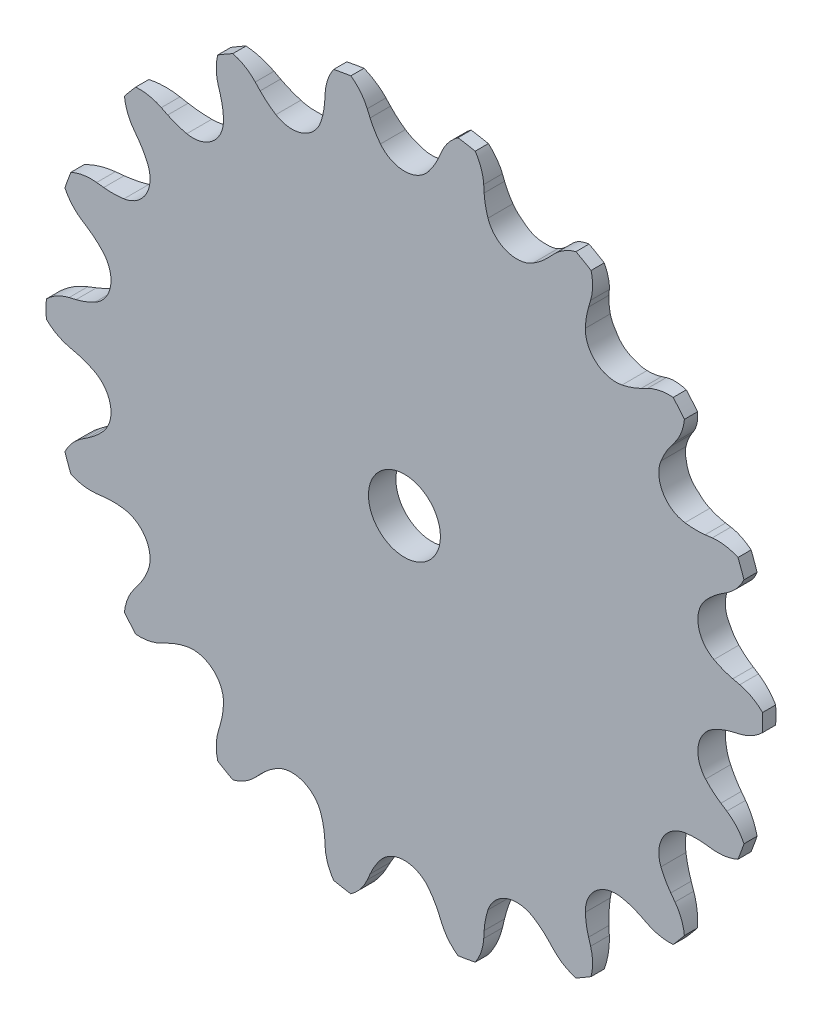
from build123d import *

# Parameters (mm, degrees)
TOOTH_CUT_NUMBER_OF_TEETH_18_DEPTH = 29.19349073
TOOTH_PATTERN_18_18_COUNT          = 18
CUT_EXTRUDE1_DEPTH                 = 29.035736303
CUT_EXTRUDE1_DEPTH_BACK            = 29.035736303
SKETCH4_R                          = 2
SKETCH7_R                          = 52.254932506
CUT_EXTRUDE2_DEPTH                 = 1.27


with BuildPart() as part:
    # Sprocket-BaseSketch → 25 _04C_ ANSI _ISO_ Chain Number_ 1.440i (revolve)
    with BuildSketch(Plane(origin=(0, 0, 0), x_dir=(0, 0, -1), z_dir=(1, 0, 0))):
        Polygon((1.397, 0), (1.397, 16.736319777), (0.60325, 19.911319777), (-0.60325, 19.911319777), (-1.397, 16.736319777), (-1.397, 0), align=None)
    revolve(axis=Axis((0, 0, -5.588), (0, 0, 1)))

    # Tooth-Sketch → Tooth-Cut_ Number of teeth_ 18 (cut, symmetric)
    with BuildSketch(Plane.XY):
        with BuildLine():
            Line((1.908645709, 18.196215131), (2.066224101, 18.559583724))
            ThreePointArc((2.066224101, 18.559583724), (3.065556725, 19.747030253), (4.552569281, 20.191427162))
            ThreePointArc((4.552569281, 20.191427162), (0, 20.69829988), (-4.552569281, 20.191427162))
            ThreePointArc((-4.552569281, 20.191427162), (-3.065556725, 19.747030253), (-2.066224101, 18.559583724))
            Line((-2.066224101, 18.559583724), (-1.908645709, 18.196215131))
            ThreePointArc((-1.908645709, 18.196215131), (-1.651424634, 17.695000021), (-1.331431851, 17.231336472))
            ThreePointArc((-1.331431851, 17.231336472), (0, 16.586741284), (1.331431851, 17.231336472))
            ThreePointArc((1.331431851, 17.231336472), (1.651424634, 17.695000021), (1.908645709, 18.196215131))
        make_face()
    tooth_cut_number_of_teeth_18 = extrude(amount=TOOTH_CUT_NUMBER_OF_TEETH_18_DEPTH, both=True, mode=Mode.SUBTRACT)

    # Tooth Pattern_ 18 _ 18: Tooth-Cut_ Number of teeth_ 18 ×18 about axis
    tooth_pattern_18_18_axis = Axis((0, 0, -88.99), (0, 0, 1))
    for i in range(1, TOOTH_PATTERN_18_18_COUNT):
        add(tooth_cut_number_of_teeth_18.rotate(tooth_pattern_18_18_axis, i * 360 / TOOTH_PATTERN_18_18_COUNT), mode=Mode.SUBTRACT)

    # Sketch4 → Cut-Extrude1 (cut, two sides: drawn at the far end of the back side and taken through both)
    with BuildSketch(Plane.XY.offset(-CUT_EXTRUDE1_DEPTH_BACK)):
        Circle(SKETCH4_R)
    extrude(amount=CUT_EXTRUDE1_DEPTH + CUT_EXTRUDE1_DEPTH_BACK, mode=Mode.SUBTRACT)

    # Sketch7 → Cut-Extrude2 (cut)
    with BuildSketch(Plane.XY.offset(1.397)):
        Circle(SKETCH7_R)
    extrude(amount=-CUT_EXTRUDE2_DEPTH, mode=Mode.SUBTRACT)


solid = part.part
